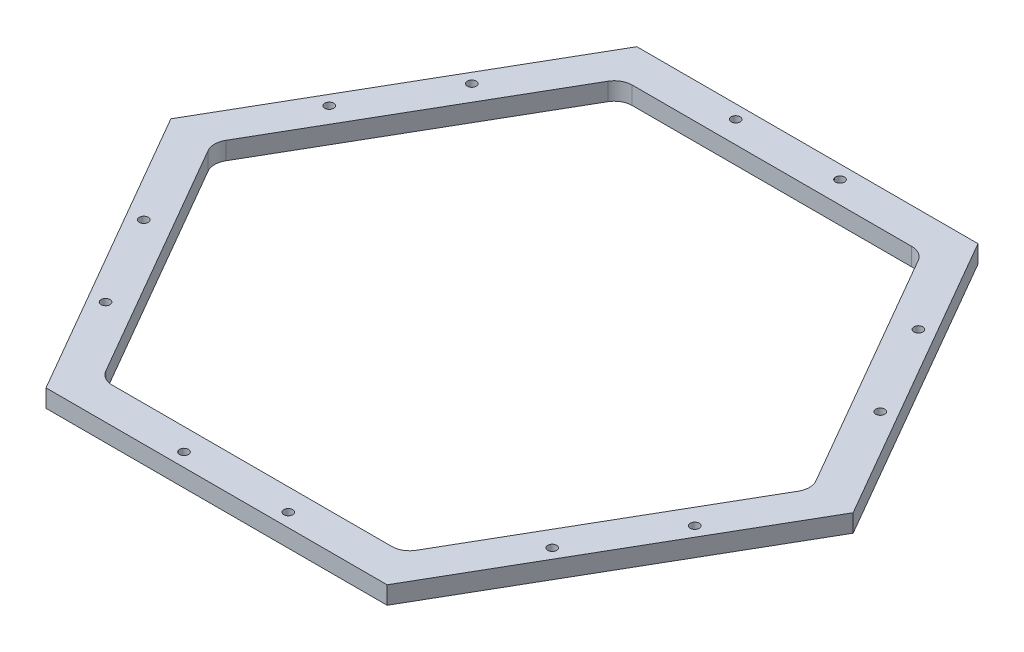
from build123d import *

# Parameters (mm, degrees)
BOSS_EXTRUDE1_DEPTH            = 3.175
M2X0_4_TAPPED_HOLE1_AT_2_COUNT = 2
M2X0_4_TAPPED_HOLE1_AT_2_PITCH = 18.662705418
CIRPATTERN1_COUNT              = 6


with BuildPart() as part:
    # Sketch1 → Boss-Extrude1 (new body)
    with BuildSketch(Plane(origin=(0, 0, 0), x_dir=(1, 0, 0), z_dir=(0, 1, 0))):
        Polygon((60.998522628, 0), (30.499261314, 52.826270189), (-30.499261314, 52.826270189), (-60.998522628, 0), (-30.499261314, -52.826270189), (30.499261314, -52.826270189), align=None)
        with BuildLine():
            Line((52.749630657, 1.5875), (27.749630657, 44.888770189))
            ThreePointArc((27.749630657, 44.888770189), (26.5875, 46.050900846), (25, 46.476270189))
            Line((25, 46.476270189), (-25, 46.476270189))
            ThreePointArc((-25, 46.476270189), (-26.5875, 46.050900846), (-27.749630657, 44.888770189))
            Line((-27.749630657, 44.888770189), (-52.749630657, 1.5875))
            ThreePointArc((-52.749630657, 1.5875), (-53.175, 0), (-52.749630657, -1.5875))
            Line((-52.749630657, -1.5875), (-27.749630657, -44.888770189))
            ThreePointArc((-27.749630657, -44.888770189), (-26.5875, -46.050900846), (-25, -46.476270189))
            Line((-25, -46.476270189), (25, -46.476270189))
            ThreePointArc((25, -46.476270189), (26.5875, -46.050900846), (27.749630657, -44.888770189))
            Line((27.749630657, -44.888770189), (52.749630657, -1.5875))
            ThreePointArc((52.749630657, -1.5875), (53.175, 0), (52.749630657, 1.5875))
        make_face(mode=Mode.SUBTRACT)
    extrude(amount=BOSS_EXTRUDE1_DEPTH)

    # Sketch2 → M2x0.4 Tapped Hole1 (revolve, cut)
    with BuildSketch(Plane(origin=(8.243943659, 3.175, -50.410234914), x_dir=(0, 0, 1), z_dir=(1, 0, 0))):
        Polygon((0, 0), (0, 6.576688495), (0.8, 6.096), (0.8, 0), align=None)
    m2x0_4_tapped_hole1 = revolve(axis=Axis((8.243943659, 9.525, -50.410234914), (0, -1, 0)), mode=Mode.SUBTRACT)

    # M2x0.4 Tapped Hole1 at 2: M2x0.4 Tapped Hole1 ×2
    with Locations(*[(-i * M2X0_4_TAPPED_HOLE1_AT_2_PITCH, 0, 0) for i in range(1, M2X0_4_TAPPED_HOLE1_AT_2_COUNT)]):
        add(m2x0_4_tapped_hole1, mode=Mode.SUBTRACT)

    # CirPattern1: M2x0.4 Tapped Hole1 ×6 about axis
    cirpattern1_axis = Axis((0, 0, 0), (0, 1, 0))
    for i in range(1, CIRPATTERN1_COUNT):
        add(m2x0_4_tapped_hole1.rotate(cirpattern1_axis, i * 360 / CIRPATTERN1_COUNT), mode=Mode.SUBTRACT)

    # CirPattern1 copy 1 sketch → CirPattern1 copy 1 (revolve, cut)
    with BuildSketch(Plane(origin=(-48.865924925, 3.175, -16.182205098), x_dir=(0.866025404, 0, 0.5), z_dir=(0.5, 0, -0.866025404))):
        Polygon((0, 0), (0, 6.576688495), (0.8, 6.096), (0.8, 0), align=None)
    revolve(axis=Axis((-48.865924925, 9.525, -16.182205098), (0, -1, 0)), mode=Mode.SUBTRACT)

    # CirPattern1 copy 2 sketch → CirPattern1 copy 2 (revolve, cut)
    with BuildSketch(Plane(origin=(-38.447163167, 3.175, 34.228029816), x_dir=(0.866025404, 0, -0.5), z_dir=(-0.5, 0, -0.866025404))):
        Polygon((0, 0), (0, 6.576688495), (0.8, 6.096), (0.8, 0), align=None)
    revolve(axis=Axis((-38.447163167, 9.525, 34.228029816), (0, -1, 0)), mode=Mode.SUBTRACT)

    # CirPattern1 copy 3 sketch → CirPattern1 copy 3 (revolve, cut)
    with BuildSketch(Plane(origin=(10.418761758, 3.175, 50.410234914), x_dir=(0, 0, -1), z_dir=(-1, 0, 0))):
        Polygon((0, 0), (0, 6.576688495), (0.8, 6.096), (0.8, 0), align=None)
    revolve(axis=Axis((10.418761758, 9.525, 50.410234914), (0, -1, 0)), mode=Mode.SUBTRACT)

    # CirPattern1 copy 4 sketch → CirPattern1 copy 4 (revolve, cut)
    with BuildSketch(Plane(origin=(48.865924925, 3.175, 16.182205098), x_dir=(-0.866025404, 0, -0.5), z_dir=(-0.5, 0, 0.866025404))):
        Polygon((0, 0), (0, 6.576688495), (0.8, 6.096), (0.8, 0), align=None)
    revolve(axis=Axis((48.865924925, 9.525, 16.182205098), (0, -1, 0)), mode=Mode.SUBTRACT)

    # CirPattern1 copy 5 sketch → CirPattern1 copy 5 (revolve, cut)
    with BuildSketch(Plane(origin=(38.447163167, 3.175, -34.228029816), x_dir=(-0.866025404, 0, 0.5), z_dir=(0.5, 0, 0.866025404))):
        Polygon((0, 0), (0, 6.576688495), (0.8, 6.096), (0.8, 0), align=None)
    revolve(axis=Axis((38.447163167, 9.525, -34.228029816), (0, -1, 0)), mode=Mode.SUBTRACT)


solid = part.part
